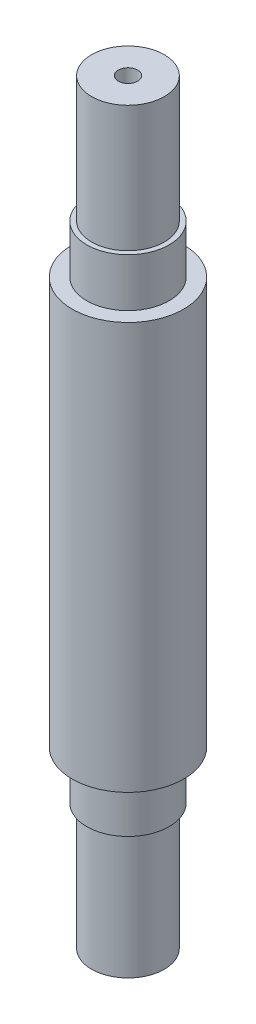
from build123d import *


with BuildPart() as part:
    # Sketch1 → Revolve1 (revolve)
    with BuildSketch(Plane.XY):
        Polygon((1, 32.461952483), (3.75, 32.461952483), (3.75, 19.461952483), (4.25, 19.461952483), (4.25, 14.461952483), (5.75, 14.461952483), (5.75, -27.538047517), (4.25, -27.538047517), (4.25, -32.538047517), (3.75, -32.538047517), (3.75, -45.538047517), (1, -45.538047517), (1, -42.538047517), (0, -41.704794599), (0, 28.461952483), (1, 29.461952483), align=None)
    revolve(axis=Axis((0, 28.461952483, 0), (0, -1, 0)))


solid = part.part
